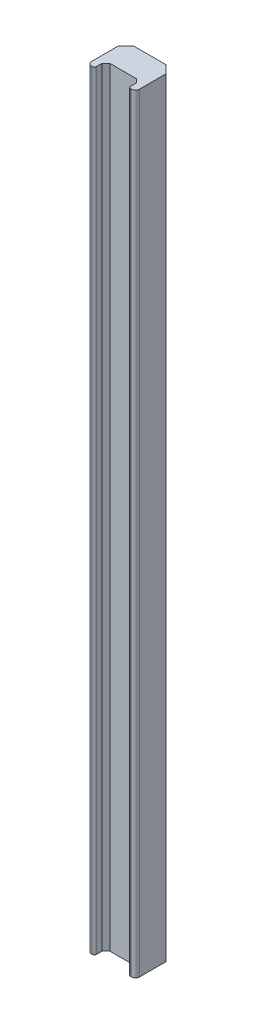
from build123d import *

# Parameters (mm, degrees)
BOSS_EXTRUDE1_DEPTH = 200
SKETCH2_W           = 12.48
SKETCH2_H           = 6
CUT_EXTRUDE1_DEPTH  = 2
CUT_EXTRUDE2_DEPTH  = 201
FILLET1_R           = 0.5


with BuildPart() as part:
    # Sketch1 → Boss-Extrude1 (new body)
    with BuildSketch(Plane(origin=(0, 0, 0), x_dir=(1, 0, 0), z_dir=(0, 1, 0))):
        with BuildLine():
            Line((0, 8), (2, 10))
            Line((2, 10), (10.48, 10))
            Line((10.48, 10), (12.48, 8))
            Line((12.48, 8), (12.48, 1))
            ThreePointArc((12.48, 1), (12.187106781, 0.292893219), (11.48, 0))
            Line((11.48, 0), (1, 0))
            ThreePointArc((1, 0), (0.292893219, 0.292893219), (0, 1))
            Line((0, 1), (0, 8))
        make_face()
    extrude(amount=BOSS_EXTRUDE1_DEPTH)

    # Sketch2 → Cut-Extrude1 (cut)
    with BuildSketch(Plane(origin=(0, 0, -10), x_dir=(-1, 0, 0), z_dir=(0, 0, -1))):
        with Locations((-6.24, 172)):
            Rectangle(SKETCH2_W, SKETCH2_H)
        with Locations((-6.24, 28)):
            Rectangle(SKETCH2_W, SKETCH2_H)
    extrude(amount=-CUT_EXTRUDE1_DEPTH, mode=Mode.SUBTRACT)

    # Sketch3 → Cut-Extrude2 (cut, through all)
    with BuildSketch(Plane.XZ):
        Polygon((1.79, 0), (1.79, -2), (2.79, -3), (9.69, -3), (10.69, -2), (10.69, 0), align=None)
    extrude(amount=-CUT_EXTRUDE2_DEPTH, mode=Mode.SUBTRACT)

    # Fillet1
    fillet1_edges = [part.edges().sort_by_distance(p)[0] for p in [
        (1.79, 100, 0),
        (10.69, 100, 0),
    ]]
    fillet(fillet1_edges, radius=FILLET1_R)


solid = part.part
